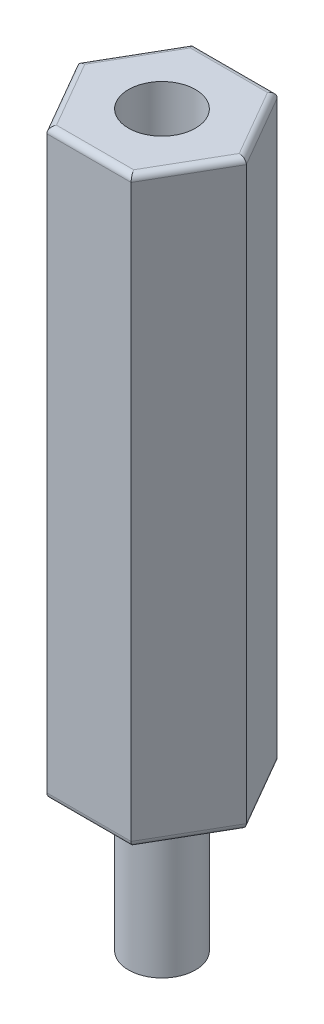
from build123d import *

# Parameters (mm, degrees)
RESSALTO_EXTRUS_O1_DEPTH = 19
FILETE1_R                = 0.2
ESBO_O2_R                = 1.0922
RESSALTO_EXTRUS_O2_DEPTH = 4.76
ESBO_O3_R                = 1.0922
CORTE_EXTRUS_O1_DEPTH    = 4.76


with BuildPart() as part:
    # Esboço1 → Ressalto-extrusão1 (new body)
    with BuildSketch(Plane(origin=(0, 0, 0), x_dir=(1, 0, 0), z_dir=(0, 1, 0))):
        Polygon((2.748187281, 0), (1.374093641, 2.38), (-1.374093641, 2.38), (-2.748187281, 0), (-1.374093641, -2.38), (1.374093641, -2.38), align=None)
    extrude(amount=RESSALTO_EXTRUS_O1_DEPTH)

    # Filete1
    filete1_edges = [part.edges().sort_by_distance(p)[0] for p in [
        (0, 19, -2.38),
        (-2.061140461, 19, -1.19),
        (-2.061140461, 19, 1.19),
        (0, 19, 2.38),
        (2.061140461, 19, 1.19),
        (0, 0, 2.38),
        (-2.061140461, 0, 1.19),
        (-2.061140461, 0, -1.19),
        (2.061140461, 19, -1.19),
        (0, 0, -2.38),
        (2.061140461, 0, -1.19),
        (2.061140461, 0, 1.19),
    ]]
    fillet(filete1_edges, radius=FILETE1_R)

    # Esboço2 → Ressalto-extrusão2 (add)
    with BuildSketch(Plane.XZ):
        Circle(ESBO_O2_R)
    extrude(amount=RESSALTO_EXTRUS_O2_DEPTH)

    # Esboço3 → Corte-extrusão1 (cut)
    with BuildSketch(Plane(origin=(0, 19, 0), x_dir=(1, 0, 0), z_dir=(0, 1, 0))):
        Circle(ESBO_O3_R)
    extrude(amount=-CORTE_EXTRUS_O1_DEPTH, mode=Mode.SUBTRACT)


solid = part.part
